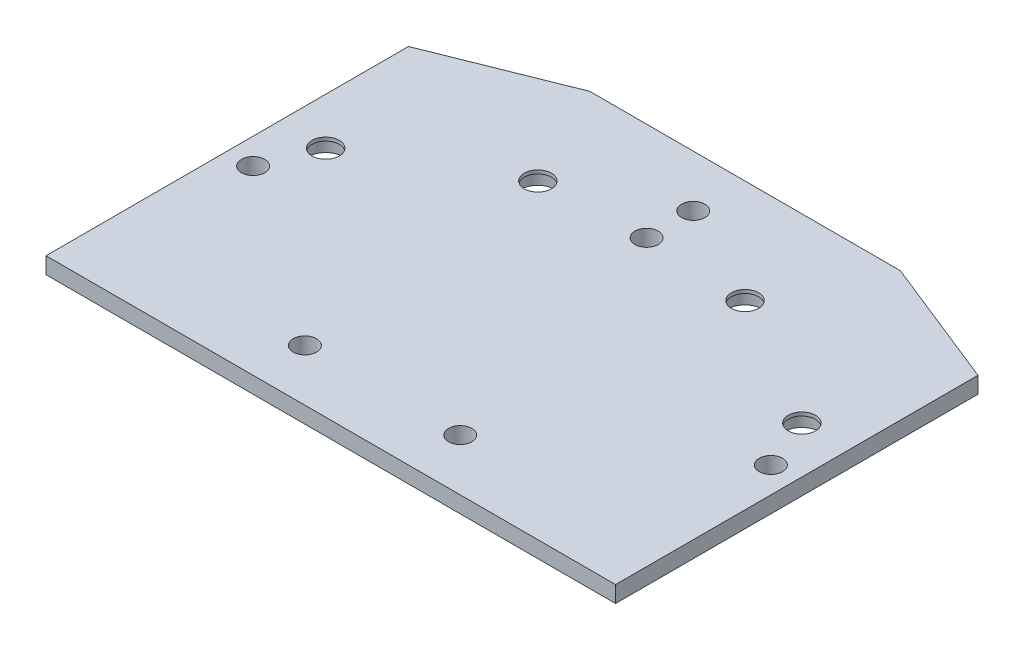
from build123d import *

# Parameters (mm, degrees)
BOSS_EXTRUDE1_DEPTH   = 1.5875
F_1_0MM_DOWEL_HOLE1_D = 5.25
SKETCH6_R             = 3.45
CUT_EXTRUDE2_DEPTH    = 2.5
M4_CLEARANCE_HOLE1_D  = 4.5
M4_CLEARANCE_HOLE2_D  = 4.5
M4_CLEARANCE_HOLE3_D  = 4.5


with BuildPart() as part:
    # Sketch1 → Boss-Extrude1 (new body, symmetric)
    with BuildSketch(Plane(origin=(0, 0, 0), x_dir=(1, 0, 0), z_dir=(0, 1, 0))):
        Polygon((-55, 15), (-30, 25), (30, 25), (55, 15), (55, -55), (-55, -55), align=None)
    extrude(amount=BOSS_EXTRUDE1_DEPTH, both=True)

    # Ø1.0mm Dowel Hole1 (through all)
    with Locations(Plane(origin=(0, 1.5875, 0), x_dir=(1, 0, 0), z_dir=(0, 1, 0))):
        with Locations((-20, 5), (20, 5), (45.980762114, -10), (-45.980762114, -10)):
            Hole(F_1_0MM_DOWEL_HOLE1_D / 2)

    # Sketch6 → Cut-Extrude2 (cut)
    with BuildSketch(Plane.XZ.offset(1.5875)):
        with Locations((-45.980762114, 10)):
            Circle(SKETCH6_R)
        with Locations((-20, -5)):
            Circle(SKETCH6_R)
        with Locations((20, -5)):
            Circle(SKETCH6_R)
        with Locations((45.980762114, 10)):
            Circle(SKETCH6_R)
    extrude(amount=-CUT_EXTRUDE2_DEPTH, mode=Mode.SUBTRACT)

    # M4 Clearance Hole1 (through all)
    with Locations(Plane(origin=(0, -1.5875, 0), x_dir=(-1, 0, 0), z_dir=(0, -1, 0))):
        with Locations((0, 15), (0, 6)):
            Hole(M4_CLEARANCE_HOLE1_D / 2)

    # M4 Clearance Hole2 (through all)
    with Locations(Plane(origin=(0, 1.5875, 0), x_dir=(1, 0, 0), z_dir=(0, 1, 0))):
        with Locations((-15, -45), (15, -45)):
            Hole(M4_CLEARANCE_HOLE2_D / 2)

    # M4 Clearance Hole3 (through all)
    with Locations(Plane(origin=(0, 1.5875, 0), x_dir=(1, 0, 0), z_dir=(0, 1, 0))):
        with Locations((-50, -20), (50, -20)):
            Hole(M4_CLEARANCE_HOLE3_D / 2)


solid = part.part
